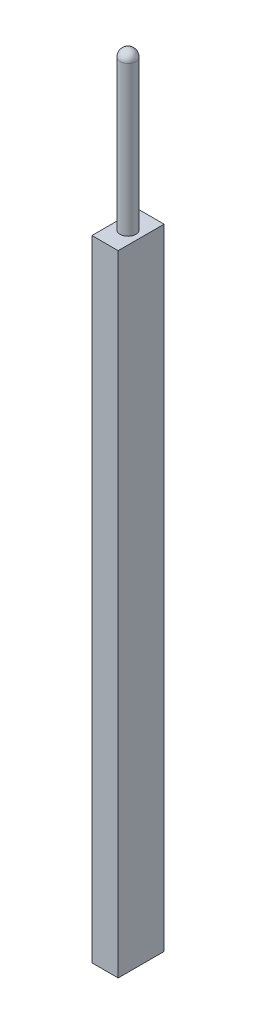
from build123d import *

# Parameters (mm, degrees)
SCHIZZO2_W                   = 5
SCHIZZO2_H                   = 8.75
ESTRUSIONE_ESTRUSIONE1_DEPTH = 120


with BuildPart() as part:
    # Schizzo1 → Rivoluzione2 (revolve)
    with BuildSketch(Plane.XY):
        with BuildLine():
            Line((-1.5, 0), (-1.5, 28.5))
            ThreePointArc((-1.5, 28.5), (-1.060660172, 29.560660172), (0, 30))
            Line((0, 30), (0, 0))
            Line((0, 0), (-1.5, 0))
        make_face()
    revolve(axis=Axis((0, 0, 0), (0, 1, 0)))

    # Schizzo2 → Estrusione-Estrusione1 (add)
    with BuildSketch(Plane.XZ):
        Rectangle(SCHIZZO2_W, SCHIZZO2_H)
    extrude(amount=ESTRUSIONE_ESTRUSIONE1_DEPTH)


solid = part.part
